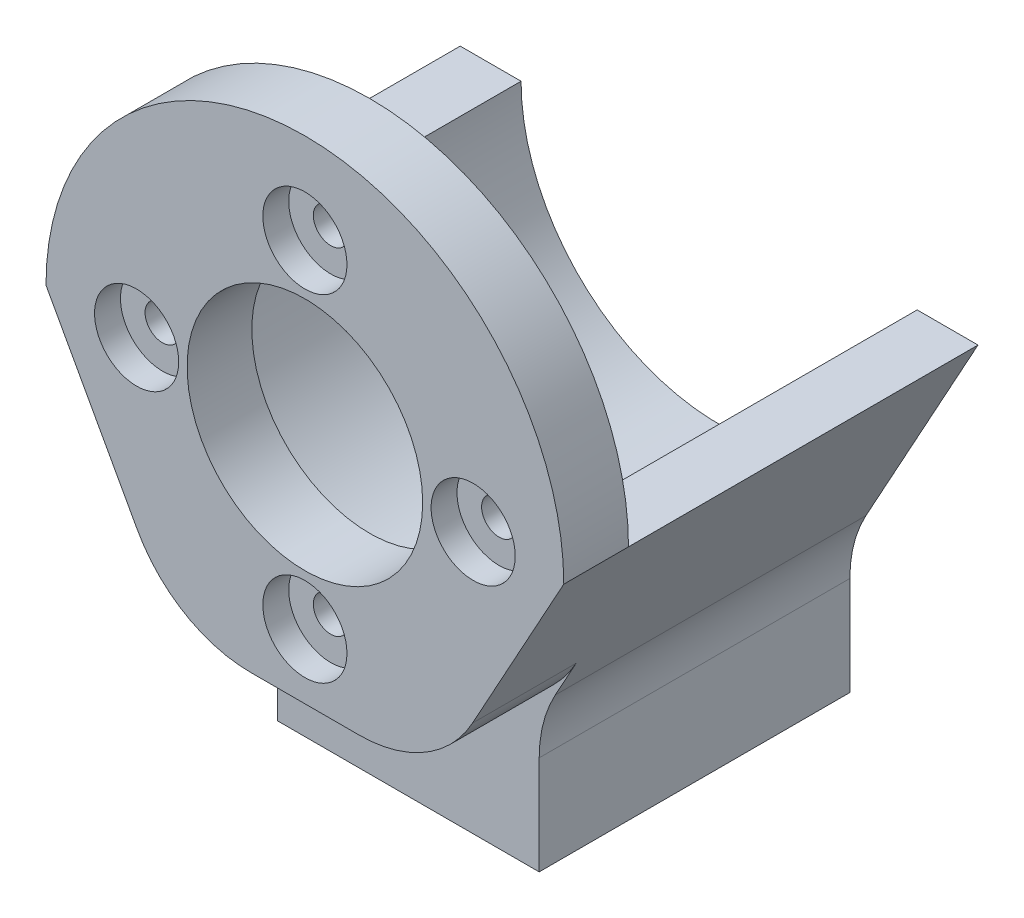
from build123d import *

# Parameters (mm, degrees)
SKETCH1_R                 = 9.1
MAIN_DEPTH                = 32
SKETCH2_R                 = 1.35
FIXHOLEMOTORS_DEPTH       = 33
HOLECIRCULARPATTERN_COUNT = 4
SKETCH3_R                 = 15.3
MOTORMAINHOLE_DEPTH       = 27
SKETCH4_W                 = 40
SKETCH4_H                 = 20
CUT_EXTRUDE3_DEPTH        = 27
SKETCH5_R                 = 3.25
HEADSCREWHOLE_DEPTH       = 2
SKETCH6_W                 = 20.2
SKETCH6_H                 = 10.2
WHEELCUT_DEPTH            = 10
SKETCH7_W                 = 20.2
SKETCH7_H                 = 10.2
SKETCH7_R                 = 1.6
BOSS_EXTRUDE2_DEPTH       = 2
FILLET1_R                 = 10
FILLET2_R                 = 10


with BuildPart() as part:
    # Sketch1 → Main (new body)
    with BuildSketch(Plane.XY):
        with BuildLine():
            Line((-5.1, -18), (-1.45, -18))
            Line((-1.45, -18), (-1.45, -19))
            Line((-1.45, -19), (1.45, -19))
            Line((1.45, -19), (1.45, -18))
            Line((1.45, -18), (5.1, -18))
            Line((5.1, -18), (5.1, -21.65))
            Line((5.1, -21.65), (4.1, -21.65))
            Line((4.1, -21.65), (4.1, -24.55))
            Line((4.1, -24.55), (5.1, -24.55))
            Line((5.1, -24.55), (5.1, -28.2))
            Line((5.1, -28.2), (10.1, -28.2))
            Line((10.1, -28.2), (10.1, -18))
            Line((10.1, -18), (20, 0))
            ThreePointArc((20, 0), (0, 20), (-20, 0))
            Line((-20, 0), (-10.1, -18))
            Line((-10.1, -18), (-10.1, -28.2))
            Line((-10.1, -28.2), (-5.1, -28.2))
            Line((-5.1, -28.2), (-5.1, -24.55))
            Line((-5.1, -24.55), (-4.1, -24.55))
            Line((-4.1, -24.55), (-4.1, -21.65))
            Line((-4.1, -21.65), (-5.1, -21.65))
            Line((-5.1, -21.65), (-5.1, -18))
        make_face()
        Circle(SKETCH1_R, mode=Mode.SUBTRACT)
    extrude(amount=MAIN_DEPTH)

    # Sketch2 → FixHoleMotors (cut, through all)
    with BuildSketch(Plane.XY.offset(32)):
        with Locations((0, 13)):
            Circle(SKETCH2_R)
    fixholemotors = extrude(amount=-FIXHOLEMOTORS_DEPTH, mode=Mode.SUBTRACT)

    # HoleCircularPattern: FixHoleMotors ×4 about axis
    holecircularpattern_axis = Axis((0, 0, 0), (0, 0, 1))
    for i in range(1, HOLECIRCULARPATTERN_COUNT):
        add(fixholemotors.rotate(holecircularpattern_axis, i * 360 / HOLECIRCULARPATTERN_COUNT), mode=Mode.SUBTRACT)

    # Sketch3 → MotorMainHole (cut)
    with BuildSketch(Plane.XY):
        Circle(SKETCH3_R)
    extrude(amount=MOTORMAINHOLE_DEPTH, mode=Mode.SUBTRACT)

    # Sketch4 → Cut-Extrude3 (cut)
    with BuildSketch(Plane(origin=(0, 0, 0), x_dir=(-1, 0, 0), z_dir=(0, 0, -1))):
        with Locations((0, 10)):
            Rectangle(SKETCH4_W, SKETCH4_H)
    extrude(amount=-CUT_EXTRUDE3_DEPTH, mode=Mode.SUBTRACT)

    # Sketch5 → HeadScrewHole (cut)
    with BuildSketch(Plane.XY.offset(32)):
        with Locations((0, 13)):
            Circle(SKETCH5_R)
        with Locations((13, 0)):
            Circle(SKETCH5_R)
        with Locations((0, -13)):
            Circle(SKETCH5_R)
        with Locations((-13, 0)):
            Circle(SKETCH5_R)
    extrude(amount=-HEADSCREWHOLE_DEPTH, mode=Mode.SUBTRACT)

    # Sketch6 → WheelCut (cut)
    with BuildSketch(Plane.XY.offset(32)):
        with Locations((0, -23.1)):
            Rectangle(SKETCH6_W, SKETCH6_H)
    extrude(amount=-WHEELCUT_DEPTH, mode=Mode.SUBTRACT)

    # Sketch7 → Boss-Extrude2 (add)
    with BuildSketch(Plane.XY.offset(22)):
        with Locations((0, -23.1)):
            Rectangle(SKETCH7_W, SKETCH7_H)
        with Locations((0, -23.15)):
            Circle(SKETCH7_R, mode=Mode.SUBTRACT)
    extrude(amount=BOSS_EXTRUDE2_DEPTH)

    # Fillet1
    fillet1_edges = [part.edges().sort_by_distance(p)[0] for p in [
        (-10.1, -18, 28),
        (10.1, -18, 28),
    ]]
    fillet(fillet1_edges, radius=FILLET1_R)

    # Fillet2
    fillet2_edges = [part.edges().sort_by_distance(p)[0] for p in [
        (-10.1, -18, 12),
        (10.1, -18, 12),
    ]]
    fillet(fillet2_edges, radius=FILLET2_R)


solid = part.part
